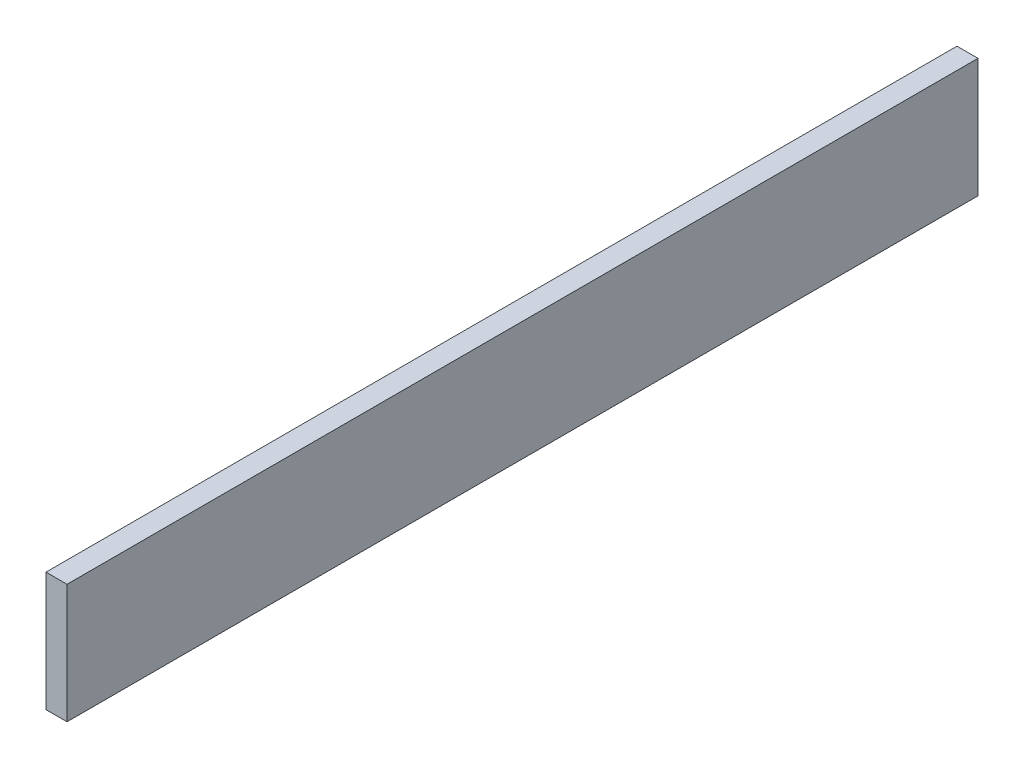
from build123d import *

# Parameters (mm, degrees)
SKETCH1_W           = 130
SKETCH1_H           = 17
BOSS_EXTRUDE1_DEPTH = 3


with BuildPart() as part:
    # Sketch1 → Boss-Extrude1 (new body)
    with BuildSketch(Plane(origin=(0, 0, 0), x_dir=(0, 0, -1), z_dir=(1, 0, 0))):
        with Locations((65, 8.5)):
            Rectangle(SKETCH1_W, SKETCH1_H)
    extrude(amount=BOSS_EXTRUDE1_DEPTH)


solid = part.part
